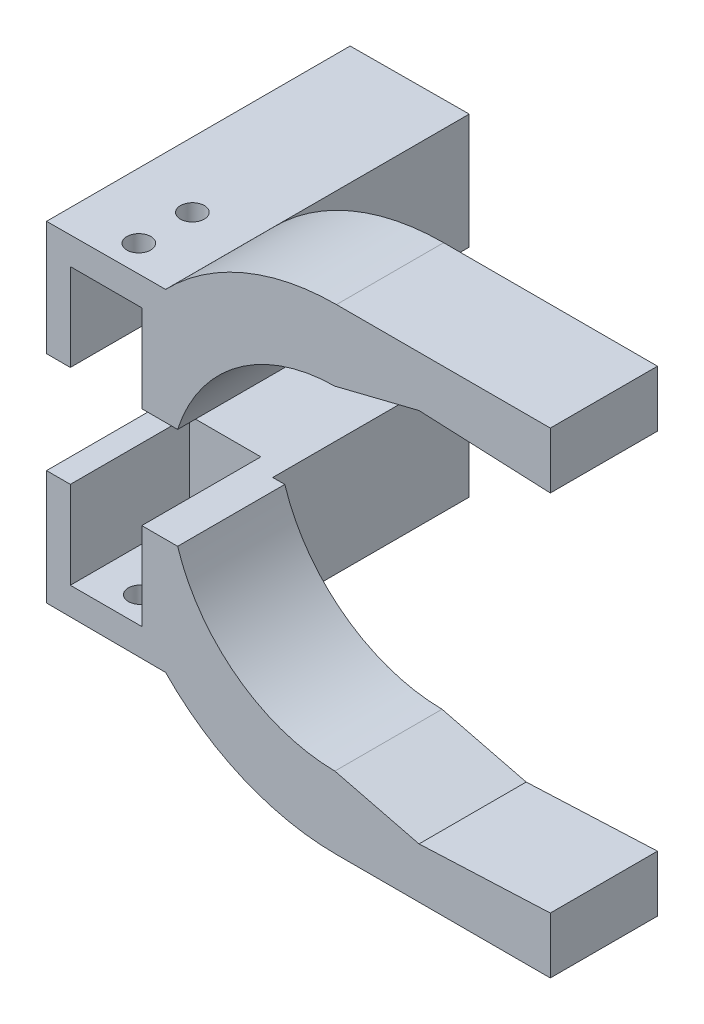
from build123d import *

# Parameters (mm, degrees)
BOSS_EXTRUDE1_DEPTH   = 18
BOSS_EXTRUDE1_2_DEPTH = 18
SKETCH3_R             = 2
CUT_EXTRUDE2_DEPTH    = 55
BOSS_EXTRUDE3_DEPTH   = 8
SKETCH6_W             = 20
SKETCH6_H             = 4
BOSS_EXTRUDE4_DEPTH   = 8
BOSS_EXTRUDE5_DEPTH   = 33
BOSS_EXTRUDE6_DEPTH   = 18
CUT_EXTRUDE3_DEPTH    = 18
FILLET1_R             = 5
CUT_EXTRUDE4_DEPTH    = 18
BOSS_EXTRUDE7_DEPTH   = 18
CUT_EXTRUDE6_DEPTH    = 18
CUT_EXTRUDE8_DEPTH    = 51
BOSS_EXTRUDE9_DEPTH   = 33
CUT_EXTRUDE9_DEPTH    = 51
SKETCH24_W            = 12
SKETCH24_H            = 10
CUT_EXTRUDE13_DEPTH   = 20
CUT_EXTRUDE14_REACH   = 70.173
SKETCH27_R            = 2
SKETCH28_W            = 12
SKETCH28_H            = 26.361153364
CUT_EXTRUDE15_DEPTH   = 20
CUT_EXTRUDE16_DEPTH   = 18


with BuildPart() as part:
    # Sketch1 → Boss-Extrude1 (new body)
    with BuildSketch(Plane.XY):
        with BuildLine():
            ThreePointArc((-67.970581872, 8.5), (-45.332107827, 51.354162441), (0, 68.5))
            Line((0, 68.5), (60, 68.5))
            Line((60, 68.5), (60, 83.5))
            Line((60, 83.5), (0, 83.5))
            ThreePointArc((0, 83.5), (-46.291853863, 69.493267774), (-77.053226258, 32.172197985))
            ThreePointArc((-77.053226258, 32.172197985), (-79.853331001, 28.774985947), (-84.067123478, 27.5))
            Line((-84.067123478, 27.5), (-103.3555905, 27.5))
            Line((-103.3555905, 27.5), (-103.3555905, 21.5))
            Line((-103.3555905, 21.5), (-83.3555905, 21.5))
            Line((-83.3555905, 21.5), (-83.3555905, 13.5))
            Line((-83.3555905, 13.5), (-103.3555905, 13.5))
            Line((-103.3555905, 13.5), (-103.3555905, 8.5))
            Line((-103.3555905, 8.5), (-67.970581872, 8.5))
        make_face()
    extrude(amount=BOSS_EXTRUDE1_DEPTH)


with BuildPart() as body_2:
    # Sketch1 → Boss-Extrude1 2 (new body)
    with BuildSketch(Plane.XY):
        with BuildLine():
            ThreePointArc((-77.053226258, -32.172197985), (-46.291853863, -69.493267774), (0, -83.5))
            Line((0, -83.5), (60, -83.5))
            Line((60, -83.5), (60, -68.5))
            Line((60, -68.5), (0, -68.5))
            ThreePointArc((0, -68.5), (-45.332107827, -51.354162441), (-67.970581872, -8.5))
            Line((-67.970581872, -8.5), (-103.3555905, -8.5))
            Line((-103.3555905, -8.5), (-103.3555905, -13.5))
            Line((-103.3555905, -13.5), (-83.3555905, -13.5))
            Line((-83.3555905, -13.5), (-83.3555905, -21.5))
            Line((-83.3555905, -21.5), (-103.3555905, -21.5))
            Line((-103.3555905, -21.5), (-103.3555905, -27.5))
            Line((-103.3555905, -27.5), (-84.067123478, -27.5))
            ThreePointArc((-84.067123478, -27.5), (-79.853331001, -28.774985947), (-77.053226258, -32.172197985))
        make_face()
    extrude(amount=BOSS_EXTRUDE1_2_DEPTH)


with BuildPart() as cut_extrude2_tool:
    # Sketch3 → Cut-Extrude2 (new body)
    with BuildSketch(Plane.XZ.offset(27.5)):
        with Locations((-88.567123478, 9)):
            Circle(SKETCH3_R)
        with Locations((-97.567123478, 9)):
            Circle(SKETCH3_R)
    extrude(amount=-CUT_EXTRUDE2_DEPTH)


with BuildPart() as part_1:
    add(part.part)

    # Cut-Extrude2: cut by cut_extrude2_tool
    add(cut_extrude2_tool.part, mode=Mode.SUBTRACT)

    # Sketch5 → Boss-Extrude3 (add)
    with BuildSketch(Plane.XZ.offset(-21.5)):
        Polygon((-103.3555905, 14), (-84.067123478, 14), (-83.3555905, 14), (-83.3555905, 18), (-103.3555905, 18), align=None)
        Polygon((-103.3555905, 4), (-103.3555905, 0), (-84.067123478, 0), (-83.3555905, 0), (-83.3555905, 4), (-84.067123478, 4), align=None)
    extrude(amount=BOSS_EXTRUDE3_DEPTH)



with BuildPart() as body_2_1:
    add(body_2.part)

    # Cut-Extrude2: cut by cut_extrude2_tool
    add(cut_extrude2_tool.part, mode=Mode.SUBTRACT)

    # Sketch6 → Boss-Extrude4 (add)
    with BuildSketch(Plane(origin=(0, -13.5, 0), x_dir=(-1, 0, 0), z_dir=(0, -1, 0))):
        with Locations((93.3555905, -16)):
            Rectangle(SKETCH6_W, SKETCH6_H)
        with Locations((93.3555905, -2)):
            Rectangle(SKETCH6_W, SKETCH6_H)
    extrude(amount=BOSS_EXTRUDE4_DEPTH)


with BuildPart() as part_2:
    add(part_1.part)

    add(body_2_1.part)  # Boss-Extrude5 merges body 2
    # Sketch7 → Boss-Extrude5 (add)
    with BuildSketch(Plane(origin=(0, 0, 0), x_dir=(-1, 0, 0), z_dir=(0, 0, -1))):
        with BuildLine():
            Line((67.970581872, -8.5), (103.3555905, -8.5))
            Line((103.3555905, -8.5), (103.3555905, -27.5))
            Line((103.3555905, -27.5), (62.737548565, -27.5))
            ThreePointArc((62.737548565, -27.5), (66.040925498, -18.189176985), (67.970581872, -8.5))
        make_face()
        with BuildLine():
            Line((103.3555905, 27.5), (62.737548565, 27.5))
            ThreePointArc((62.737548565, 27.5), (66.040925498, 18.189176985), (67.970581872, 8.5))
            Line((67.970581872, 8.5), (103.3555905, 8.5))
            Line((103.3555905, 8.5), (103.3555905, 27.5))
        make_face()
    extrude(amount=BOSS_EXTRUDE5_DEPTH)

    # Sketch9 → Boss-Extrude6 (add)
    with BuildSketch(Plane.XY.offset(18)):
        with BuildLine():
            Line((-67.970581872, 8.5), (-53.326822519, 8.5))
            ThreePointArc((-53.326822519, 8.5), (-35.049964337, 41.079191813), (0, 54))
            Line((0, 54), (60, 54))
            Line((60, 54), (60, 68.5))
            Line((60, 68.5), (0, 68.5))
            ThreePointArc((0, 68.5), (-45.332107827, 51.354162441), (-67.970581872, 8.5))
        make_face()
        with BuildLine():
            Line((0, -54), (60, -54))
            Line((60, -54), (60, -68.5))
            Line((60, -68.5), (0, -68.5))
            ThreePointArc((0, -68.5), (-45.332107827, -51.354162441), (-67.970581872, -8.5))
            Line((-67.970581872, -8.5), (-53.326822519, -8.5))
            ThreePointArc((-53.326822519, -8.5), (-35.049964337, -41.079191813), (0, -54))
        make_face()
    extrude(amount=-BOSS_EXTRUDE6_DEPTH)

    # Sketch10 → Cut-Extrude3 (cut)
    with BuildSketch(Plane.XY.offset(18)):
        with BuildLine():
            ThreePointArc((0, 83.5), (-46.291853863, 69.493267774), (-77.053226258, 32.172197985))
            Line((-77.053226258, 32.172197985), (-66.08479157, 32.172197985))
            ThreePointArc((-66.08479157, 32.172197985), (-38.971742635, 62.317359347), (0, 73.5))
            Line((0, 73.5), (50, 73.5))
            Line((50, 73.5), (60, 73.5))
            Line((60, 73.5), (60, 83.5))
            Line((60, 83.5), (0, 83.5))
        make_face()
        with BuildLine():
            Line((0, -83.5), (60, -83.5))
            Line((60, -83.5), (60, -73.5))
            Line((60, -73.5), (50, -73.5))
            Line((50, -73.5), (0, -73.5))
            ThreePointArc((0, -73.5), (-38.971742635, -62.317359347), (-66.08479157, -32.172197985))
            Line((-66.08479157, -32.172197985), (-77.053226258, -32.172197985))
            ThreePointArc((-77.053226258, -32.172197985), (-46.291853863, -69.493267774), (0, -83.5))
        make_face()
        with BuildLine():
            Line((0, -56), (60, -56))
            Line((60, -56), (60, -54))
            Line((60, -54), (0, -54))
            ThreePointArc((0, -54), (-35.049964337, -41.079191813), (-53.326822519, -8.5))
            Line((-53.326822519, -8.5), (-55.35115175, -8.5))
            ThreePointArc((-55.35115175, -8.5), (-36.469165058, -42.497058722), (0, -56))
        make_face()
        with BuildLine():
            Line((60, 54), (60, 56))
            Line((60, 56), (0, 56))
            ThreePointArc((0, 56), (-36.469165058, 42.497058722), (-55.35115175, 8.5))
            Line((-55.35115175, 8.5), (-53.326822519, 8.5))
            ThreePointArc((-53.326822519, 8.5), (-35.049964337, 41.079191813), (0, 54))
            Line((0, 54), (60, 54))
        make_face()
    extrude(amount=-CUT_EXTRUDE3_DEPTH, mode=Mode.SUBTRACT)

    # Fillet1
    fillet1_edges = [part_2.edges().sort_by_distance(p)[0] for p in [
        (-77.053226258, 32.172197985, 9),
    ]]
    fillet(fillet1_edges, radius=FILLET1_R)

    # Sketch12 → Cut-Extrude4 (cut)
    with BuildSketch(Plane.XY.offset(18)):
        with BuildLine():
            ThreePointArc((-84.067123478, 27.5), (-74.733138383, 28.516658422), (-66.08479157, 32.172197985))
            Line((-66.08479157, 32.172197985), (-74.273414579, 32.172197985))
            ThreePointArc((-74.273414579, 32.172197985), (-76.4262848, 31.684974271), (-78.159583252, 30.318257909))
            ThreePointArc((-78.159583252, 30.318257909), (-80.794448382, 28.24065074), (-84.067123478, 27.5))
        make_face()
        with BuildLine():
            ThreePointArc((-84.067123478, -27.5), (-74.733138383, -28.516658422), (-66.08479157, -32.172197985))
            Line((-66.08479157, -32.172197985), (-77.053226258, -32.172197985))
            ThreePointArc((-77.053226258, -32.172197985), (-79.853331001, -28.774985947), (-84.067123478, -27.5))
        make_face()
    extrude(amount=-CUT_EXTRUDE4_DEPTH, mode=Mode.SUBTRACT)

    # Sketch13 → Boss-Extrude7 (add)
    with BuildSketch(Plane.XY.offset(18)):
        with BuildLine():
            ThreePointArc((-0.27090305, 27.998689461), (-0.13545311, 27.999672363), (0, 28))
            Line((0, 28), (35.921954013, 28))
            Line((35.921954013, 28), (35.921954013, 40))
            Line((35.921954013, 40), (0, 40))
            ThreePointArc((0, 40), (-15.581300739, 36.84050851), (-28.701152124, 27.861153364))
            Line((-28.701152124, 27.861153364), (-59.086442662, 27.714159426))
            Line((-59.086442662, 27.714159426), (-59.086442662, 8.5))
            Line((-59.086442662, 8.5), (-39.086442662, 8.5))
            Line((-39.086442662, 8.5), (-26.678643144, 8.5))
            ThreePointArc((-26.678643144, 8.5), (-16.631873998, 22.525114146), (-0.27090305, 27.998689461))
        make_face()
        with BuildLine():
            Line((35.921954013, -28), (0, -28))
            ThreePointArc((0, -28), (-0.13545311, -27.999672363), (-0.27090305, -27.998689461))
            ThreePointArc((-0.27090305, -27.998689461), (-16.631873998, -22.525114146), (-26.678643144, -8.5))
            Line((-26.678643144, -8.5), (-39.086442662, -8.5))
            Line((-39.086442662, -8.5), (-55.35115175, -8.5))
            ThreePointArc((-55.35115175, -8.5), (-52.876575307, -18.44092687), (-48.632495811, -27.764732147))
            Line((-48.632495811, -27.764732147), (-28.701152124, -27.861153364))
            ThreePointArc((-28.701152124, -27.861153364), (-15.581300739, -36.84050851), (0, -40))
            Line((0, -40), (35.921954013, -40))
            Line((35.921954013, -40), (35.921954013, -28))
        make_face()
    extrude(amount=-BOSS_EXTRUDE7_DEPTH)

    # Sketch14 → Cut-Extrude6 (cut)
    with BuildSketch(Plane.XY.offset(18)):
        with BuildLine():
            Line((60, -40), (0, -40))
            ThreePointArc((0, -40), (-15.581300739, -36.84050851), (-28.701152124, -27.861153364))
            Line((-28.701152124, -27.861153364), (-103.3555905, -27.5))
            Line((-103.3555905, -27.5), (-103.3555905, -78.529731722))
            Line((-103.3555905, -78.529731722), (60, -73.5))
            Line((60, -73.5), (60, -40))
        make_face()
        with BuildLine():
            Line((0, 40), (76.426770392, 40))
            Line((76.426770392, 40), (76.426770392, 83.735898263))
            Line((76.426770392, 83.735898263), (-103.3555905, 83.735898263))
            Line((-103.3555905, 83.735898263), (-103.3555905, 27.5))
            Line((-103.3555905, 27.5), (-28.701152124, 27.861153364))
            ThreePointArc((-28.701152124, 27.861153364), (-15.581300739, 36.84050851), (0, 40))
        make_face()
    extrude(amount=-CUT_EXTRUDE6_DEPTH, mode=Mode.SUBTRACT)

    # Sketch16 → Cut-Extrude8 (cut)
    with BuildSketch(Plane.XY.offset(18)):
        Polygon((-96.511114913, -8.5), (-48.701152124, -8.5), (-48.701152124, 27.76440001), (-96.511114913, 27.533111298), align=None)
        with BuildLine():
            Line((-59.086442662, -27.714159426), (-48.701152124, -27.76440001))
            Line((-48.701152124, -27.76440001), (-48.701152124, -8.5))
            Line((-48.701152124, -8.5), (-96.511114913, -8.5))
            Line((-96.511114913, -8.5), (-96.511114913, -27.5))
            Line((-96.511114913, -27.5), (-84.067123478, -27.5))
            ThreePointArc((-84.067123478, -27.5), (-81.983393161, -27.489607176), (-79.903320582, -27.613454288))
            Line((-79.903320582, -27.613454288), (-59.086442662, -27.714159426))
        make_face()
    extrude(amount=-CUT_EXTRUDE8_DEPTH, mode=Mode.SUBTRACT)

    # Sketch17 → Boss-Extrude9 (add)
    with BuildSketch(Plane(origin=(0, 0, 0), x_dir=(-1, 0, 0), z_dir=(0, 0, -1))):
        Polygon((48.701152124, 8.5), (48.701152124, 27.76440001), (28.701152124, 27.861153364), (28.701152124, 8.5), align=None)
        Polygon((48.701152124, -8.5), (28.701152124, -8.5), (28.701152124, -27.861153364), (48.701152124, -27.76440001), align=None)
    extrude(amount=BOSS_EXTRUDE9_DEPTH)

    # Sketch18 → Cut-Extrude9 (cut)
    with BuildSketch(Plane.XY.offset(18)):
        Polygon((-48.701152124, 27.76440001), (-116.673009187, 35.475699467), (-116.673009187, -41.632003062), (-48.701152124, -27.76440001), align=None)
    extrude(amount=-CUT_EXTRUDE9_DEPTH, mode=Mode.SUBTRACT)

    # Sketch24 → Cut-Extrude13 (cut)
    with BuildSketch(Plane.XY.offset(18)):
        with Locations((-38.701152124, -18.180576682)):
            Rectangle(SKETCH24_W, SKETCH24_H)
        with Locations((-38.701152124, 18.180576682)):
            Rectangle(SKETCH24_W, SKETCH24_H)
    extrude(amount=-CUT_EXTRUDE13_DEPTH, mode=Mode.SUBTRACT)

    # Cut-Extrude14: up to this face of the body (flat: up to its plane)
    cut_extrude14_end = Plane(part_2.part.faces().sort_by_distance((-38.701152124, -27.812776687, -7.5))[0])
    # Sketch27 → Cut-Extrude14 (cut, up to the picked face)
    with BuildSketch(Plane(origin=(-0.135451525, 27.999344731, 0), x_dir=(0.999988299, 0.004837611, 0), z_dir=(-0.004837611, 0.999988299, 0)), mode=Mode.PRIVATE) as cut_extrude14_sk1:
        with Locations((-37.566034859, -13.5)):
            Circle(SKETCH27_R)
    cut_extrude14_tool1 = split(extrude(cut_extrude14_sk1.sketch, amount=-CUT_EXTRUDE14_REACH, mode=Mode.PRIVATE), bisect_by=cut_extrude14_end, keep=Keep.BOTH, mode=Mode.PRIVATE)
    add(cut_extrude14_tool1.solids().sort_by_distance((-37.701047, 27.817615, 13.5))[0], mode=Mode.SUBTRACT)
    # Sketch27 → Cut-Extrude14 (cut, up to the picked face)
    with BuildSketch(Plane(origin=(-0.135451525, 27.999344731, 0), x_dir=(0.999988299, 0.004837611, 0), z_dir=(-0.004837611, 0.999988299, 0)), mode=Mode.PRIVATE) as cut_extrude14_sk2:
        with Locations((-37.566034859, -4.5)):
            Circle(SKETCH27_R)
    cut_extrude14_tool2 = split(extrude(cut_extrude14_sk2.sketch, amount=-CUT_EXTRUDE14_REACH, mode=Mode.PRIVATE), bisect_by=cut_extrude14_end, keep=Keep.BOTH, mode=Mode.PRIVATE)
    add(cut_extrude14_tool2.solids().sort_by_distance((-37.701047, 27.817615, 4.5))[0], mode=Mode.SUBTRACT)

    # Sketch28 → Cut-Extrude15 (cut)
    with BuildSketch(Plane.XY.offset(18)):
        with Locations((-38.701152124, 0)):
            Rectangle(SKETCH28_W, SKETCH28_H)
    extrude(amount=-CUT_EXTRUDE15_DEPTH, mode=Mode.SUBTRACT)

    # Sketch29 → Cut-Extrude16 (cut)
    with BuildSketch(Plane.XY.offset(18)):
        Polygon((35.921954013, 28), (35.921954013, 30.548024479), (13.866014887, 31.522263692), (-0.27090305, 27.998689461), align=None)
        Polygon((35.921954013, -28), (35.921954013, -30.548024479), (13.866014887, -31.522263692), (-0.27090305, -27.998689461), align=None)
    extrude(amount=-CUT_EXTRUDE16_DEPTH, mode=Mode.SUBTRACT)


solid = part_2.part
